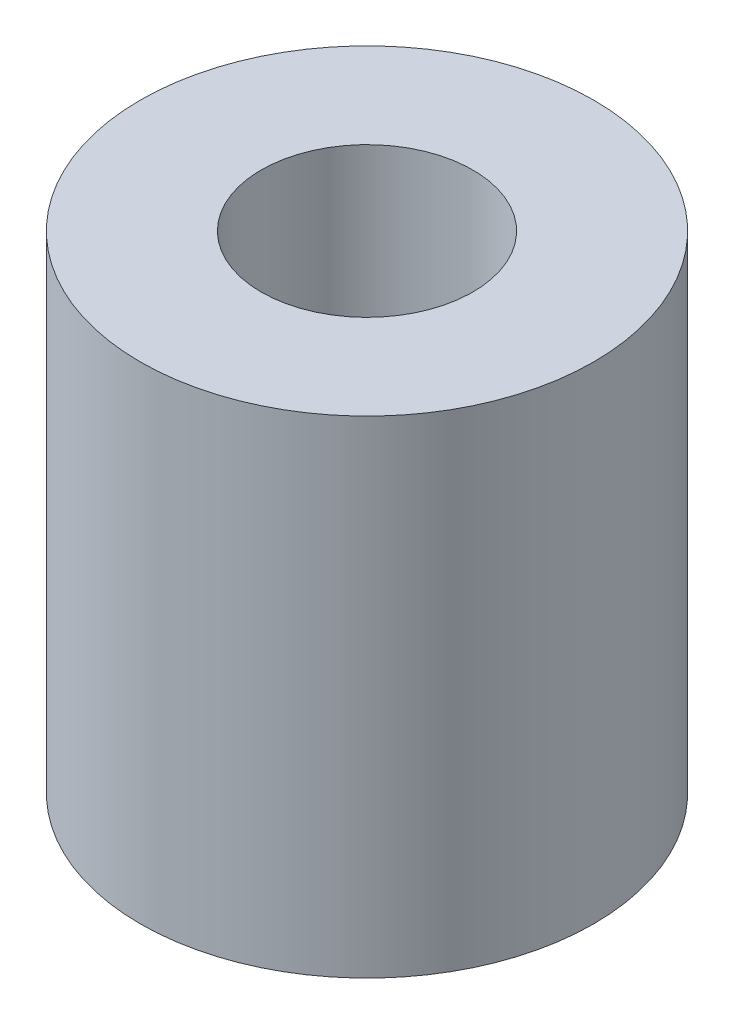
from build123d import *

# Parameters (mm, degrees)
SKETCH1_R           = 3.75
SKETCH1_R_2         = 1.75
BOSS_EXTRUDE1_DEPTH = 8.05


with BuildPart() as part:
    # Sketch1 → Boss-Extrude1 (new body)
    with BuildSketch(Plane(origin=(0, 0, 0), x_dir=(1, 0, 0), z_dir=(0, 1, 0))):
        Circle(SKETCH1_R)
        Circle(SKETCH1_R_2, mode=Mode.SUBTRACT)
    extrude(amount=BOSS_EXTRUDE1_DEPTH)


solid = part.part
